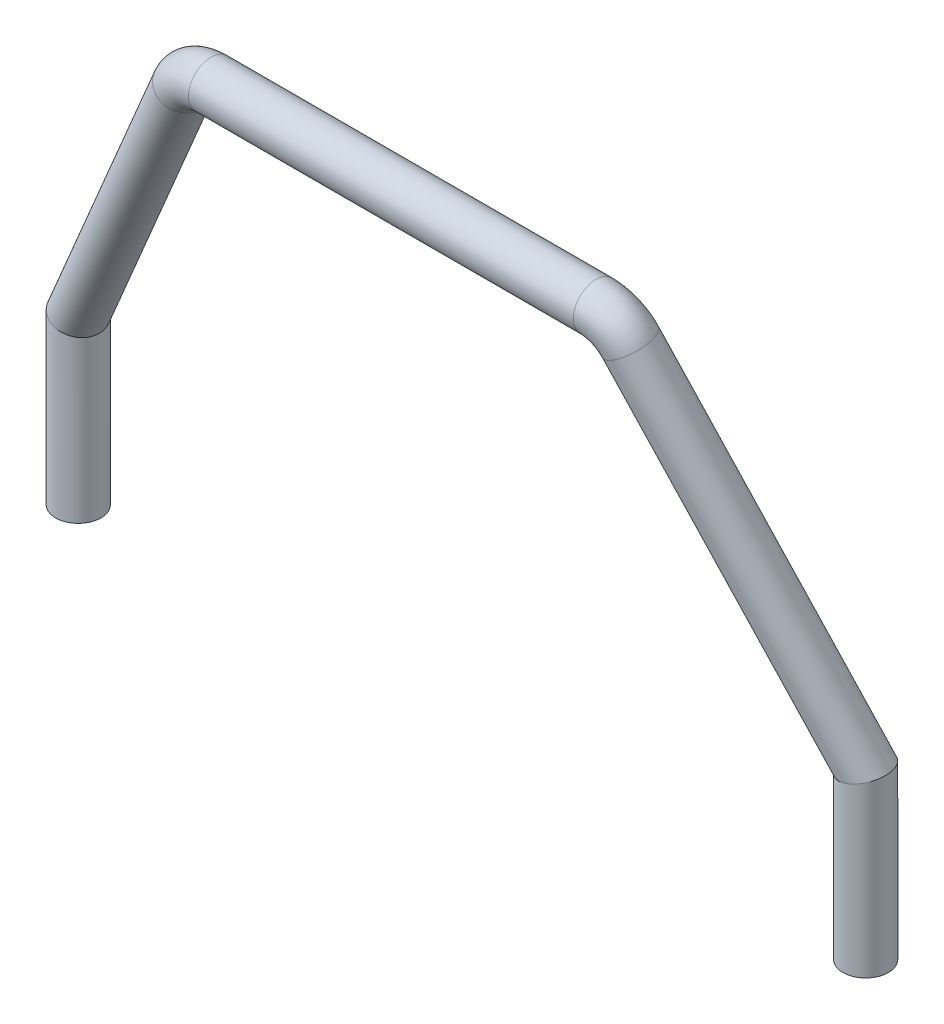
from build123d import *

# Parameters (mm, degrees)
CROQUIS2_R = 3.25


with BuildPart() as part:
    # Barrer2: sweep along a curve in space
    with BuildLine() as barrer2_path:
        Line((-27.572352062, 71.613970134, 9.809651149), (0, 71.613970134, 9.809651149))
        ThreePointArc((-31.991027423, 69.008310978, 9.274420134), (-30.151141692, 70.912292174, 9.665518788), (-27.572352062, 71.613970134, 9.809651149))
        Line((-56.4, 23.857755349, 0), (-31.991027423, 69.008310978, 9.274420134))
        Line((-56.4, 0, 0), (-56.4, 23.857755349, 0))
    # Croquis2 → Barrer2 (sweep)
    with BuildSketch(Plane(origin=(0, 0, 0), x_dir=(1, 0, 0), z_dir=(0, 1, 0))):
        with Locations((-56.4, 0)):
            Circle(CROQUIS2_R)
    barrer2 = sweep(path=barrer2_path.line, transition=Transition.RIGHT)

    # Simetría1: Barrer2 across Right Plane
    add(barrer2.mirror(Plane(origin=(0, 0, 0), x_dir=(0, 0, -1), z_dir=(1, 0, 0))))


solid = part.part
